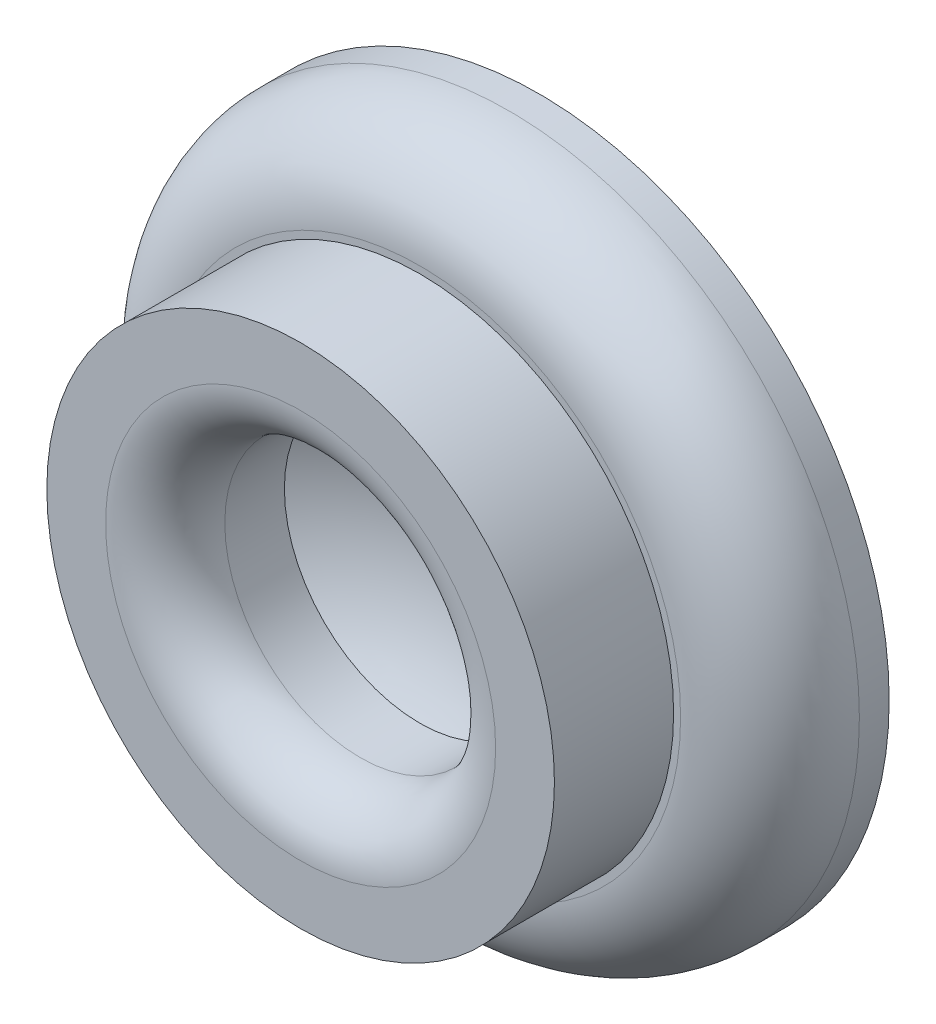
from build123d import *

# Parameters (mm, degrees)
SKETCH1_R           = 17.628998489
BOSS_EXTRUDE1_DEPTH = 6
SKETCH2_R           = 12.777406612
SKETCH2_R_2         = 6.818235005
BOSS_EXTRUDE2_DEPTH = 6
FILLET1_R           = 4.5
FILLET2_R           = 3
DOME1_FACE_RADIUS   = 6.818235005
DOME1_HEIGHT        = 2


with BuildPart() as part:
    # Sketch1 → Boss-Extrude1 (new body)
    with BuildSketch(Plane.XY):
        Circle(SKETCH1_R)
    extrude(amount=BOSS_EXTRUDE1_DEPTH)

    # Sketch2 → Boss-Extrude2 (add)
    with BuildSketch(Plane.XY.offset(6)):
        Circle(SKETCH2_R)
        Circle(SKETCH2_R_2, mode=Mode.SUBTRACT)
    extrude(amount=BOSS_EXTRUDE2_DEPTH)

    # Fillet1
    fillet1_edges = [part.edges().sort_by_distance(p)[0] for p in [
        (-17.628998489, 0, 6),
    ]]
    fillet(fillet1_edges, radius=FILLET1_R)

    # Fillet2
    fillet2_edges = [part.edges().sort_by_distance(p)[0] for p in [
        (-6.818235005, 0, 12),
    ]]
    fillet(fillet2_edges, radius=FILLET2_R)

    # Dome1: a dome of height H over a round flat face of radius A is a cap of a sphere of radius (A * A + H * H) / (2 * H)
    dome1_r = (DOME1_FACE_RADIUS * DOME1_FACE_RADIUS + DOME1_HEIGHT * DOME1_HEIGHT) / (2 * DOME1_HEIGHT)
    dome1_base = Plane((0, 0, 6), z_dir=(0, 0, -1))
    with Locations(dome1_base.offset(DOME1_HEIGHT - dome1_r)):
        dome1_ball = Sphere(dome1_r, mode=Mode.PRIVATE)
    add(split(dome1_ball, bisect_by=dome1_base, keep=Keep.TOP, mode=Mode.PRIVATE), mode=Mode.SUBTRACT)


solid = part.part
